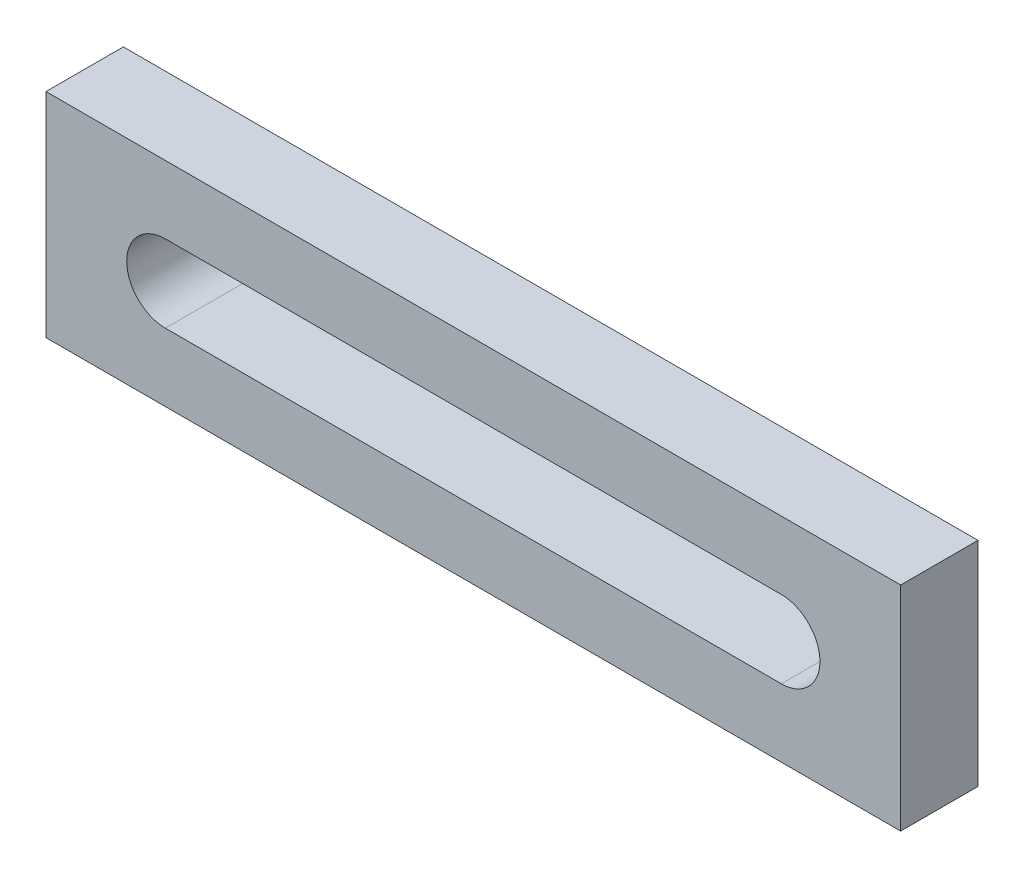
from build123d import *

# Parameters (mm, degrees)
SKETCH1_W           = 110.510118672
SKETCH1_H           = 27.56100364
BOSS_EXTRUDE1_DEPTH = 10


with BuildPart() as part:
    # Sketch1 → Boss-Extrude1 (new body)
    with BuildSketch(Plane.XY):
        with Locations((55.255059336, 13.78050182)):
            Rectangle(SKETCH1_W, SKETCH1_H)
        with BuildLine():
            Line((15.435752348, 18.78050182), (95.074366324, 18.78050182))
            ThreePointArc((95.074366324, 18.78050182), (100.074366324, 13.78050182), (95.074366324, 8.78050182))
            Line((95.074366324, 8.78050182), (15.435752348, 8.78050182))
            ThreePointArc((15.435752348, 8.78050182), (10.435752348, 13.78050182), (15.435752348, 18.78050182))
        make_face(mode=Mode.SUBTRACT)
    extrude(amount=BOSS_EXTRUDE1_DEPTH)


solid = part.part
